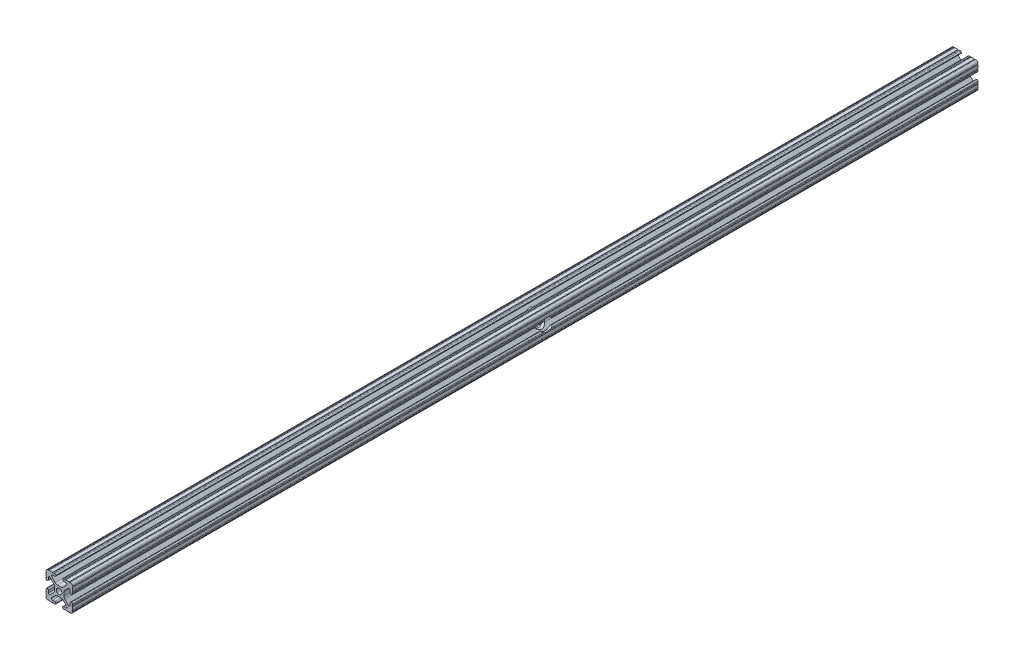
from build123d import *

# Parameters (mm, degrees)
SKETCH1_R               = 2.6035
EXTRUDE1_DEPTH          = 1219.2
SKETCH2_W               = 67.562409857
SKETCH2_H               = 369.908237117
CUT_EXTRUDE2_DEPTH      = 26.4
SKETCH3_R               = 6
CUT_EXTRUDE3_DEPTH      = 9.1915
CUT_EXTRUDE3_DEPTH_BACK = 18.2085


with BuildPart() as part:
    # Sketch1 → Extrude1 (new body)
    with BuildSketch(Plane.XY):
        with BuildLine():
            Line((-7.207036008, 8.724370562), (-3.898272566, 5.423169045))
            ThreePointArc((-3.898272566, 5.423169045), (-2.869120213, 4.736787962), (-1.655778399, 4.4958))
            Line((-1.655778399, 4.4958), (1.655778399, 4.4958))
            ThreePointArc((1.655778399, 4.4958), (2.869120213, 4.736787962), (3.898272566, 5.423169045))
            Line((3.898272566, 5.423169045), (7.207036008, 8.724370562))
            ThreePointArc((7.207036008, 8.724370562), (7.432222385, 9.85140422), (6.476788598, 10.4902))
            Line((6.476788598, 10.4902), (4.287512407, 10.4902))
            ThreePointArc((4.287512407, 10.4902), (3.54574862, 10.79744862), (3.2385, 11.539212407))
            Line((3.2385, 11.539212407), (3.2385, 11.650987593))
            ThreePointArc((3.2385, 11.650987593), (3.54574862, 12.39275138), (4.287512407, 12.7))
            Line((4.287512407, 12.7), (5.317126718, 12.7))
            ThreePointArc((5.317126718, 12.7), (5.825126718, 12.192), (6.333126718, 12.7))
            Line((6.333126718, 12.7), (9.550443118, 12.7))
            ThreePointArc((9.550443118, 12.7), (10.058366869, 12.192000006), (10.566443095, 12.699847501))
            ThreePointArc((10.566443095, 12.699847501), (12.082537762, 12.08250727), (12.699846982, 10.566399977))
            ThreePointArc((12.699846982, 10.566399977), (12.192000006, 10.058323491), (12.7, 9.5504))
            Line((12.7, 9.5504), (12.7, 6.3330836))
            ThreePointArc((12.7, 6.3330836), (12.192, 5.8250836), (12.7, 5.3170836))
            Line((12.7, 5.3170836), (12.7, 4.287469289))
            ThreePointArc((12.7, 4.287469289), (12.39275138, 3.545705502), (11.650987593, 3.238456882))
            Line((11.650987593, 3.238456882), (11.539212407, 3.238456882))
            ThreePointArc((11.539212407, 3.238456882), (10.79744862, 3.545705502), (10.4902, 4.287469289))
            Line((10.4902, 4.287469289), (10.4902, 6.402089023))
            ThreePointArc((10.4902, 6.402089023), (9.856505071, 7.351067942), (8.737131347, 7.129408934))
            Line((8.737131347, 7.129408934), (5.441005833, 3.840816462))
            ThreePointArc((5.441005833, 3.840816462), (4.750877967, 2.809883091), (4.5085, 1.593185507))
            Line((4.5085, 1.593185507), (4.5085, -1.593185507))
            ThreePointArc((4.5085, -1.593185507), (4.750877967, -2.809883091), (5.441005833, -3.840816462))
            Line((5.441005833, -3.840816462), (8.737131347, -7.129408934))
            ThreePointArc((8.737131347, -7.129408934), (9.856505071, -7.351067942), (10.4902, -6.402089023))
            Line((10.4902, -6.402089023), (10.4902, -4.287469289))
            ThreePointArc((10.4902, -4.287469289), (10.79744862, -3.545705502), (11.539212407, -3.238456882))
            Line((11.539212407, -3.238456882), (11.650987593, -3.238456882))
            ThreePointArc((11.650987593, -3.238456882), (12.39275138, -3.545705502), (12.7, -4.287469289))
            Line((12.7, -4.287469289), (12.7, -5.3170836))
            ThreePointArc((12.7, -5.3170836), (12.192, -5.8250836), (12.7, -6.3330836))
            Line((12.7, -6.3330836), (12.7, -9.5504))
            ThreePointArc((12.7, -9.5504), (12.192000006, -10.058323491), (12.699846982, -10.566399977))
            ThreePointArc((12.699846982, -10.566399977), (12.082537762, -12.08250727), (10.566443095, -12.699847501))
            ThreePointArc((10.566443095, -12.699847501), (10.058366869, -12.192000006), (9.550443118, -12.7))
            Line((9.550443118, -12.7), (6.333126718, -12.7))
            ThreePointArc((6.333126718, -12.7), (5.825126718, -12.192), (5.317126718, -12.7))
            Line((5.317126718, -12.7), (4.287512407, -12.7))
            ThreePointArc((4.287512407, -12.7), (3.54574862, -12.39275138), (3.2385, -11.650987593))
            Line((3.2385, -11.650987593), (3.2385, -11.539212407))
            ThreePointArc((3.2385, -11.539212407), (3.54574862, -10.79744862), (4.287512407, -10.4902))
            Line((4.287512407, -10.4902), (6.416408329, -10.4902))
            ThreePointArc((6.416408329, -10.4902), (7.41473083, -9.822813117), (7.179650497, -8.645192506))
            Line((7.179650497, -8.645192506), (3.952270251, -5.423690499))
            ThreePointArc((3.952270251, -5.423690499), (2.922936451, -4.736929036), (1.709253557, -4.4958))
            Line((1.709253557, -4.4958), (-1.709253557, -4.4958))
            ThreePointArc((-1.709253557, -4.4958), (-2.922936451, -4.736929036), (-3.952270251, -5.423690499))
            Line((-3.952270251, -5.423690499), (-7.179650497, -8.645192506))
            ThreePointArc((-7.179650497, -8.645192506), (-7.41473083, -9.822813117), (-6.416408329, -10.4902))
            Line((-6.416408329, -10.4902), (-4.287512407, -10.4902))
            ThreePointArc((-4.287512407, -10.4902), (-3.54574862, -10.79744862), (-3.2385, -11.539212407))
            Line((-3.2385, -11.539212407), (-3.2385, -11.650987593))
            ThreePointArc((-3.2385, -11.650987593), (-3.54574862, -12.39275138), (-4.287512407, -12.7))
            Line((-4.287512407, -12.7), (-5.317126718, -12.7))
            ThreePointArc((-5.317126718, -12.7), (-5.825126718, -12.192), (-6.333126718, -12.7))
            Line((-6.333126718, -12.7), (-9.550443118, -12.7))
            ThreePointArc((-9.550443118, -12.7), (-10.058366869, -12.192000006), (-10.566443095, -12.699847501))
            ThreePointArc((-10.566443095, -12.699847501), (-12.082537762, -12.08250727), (-12.699846982, -10.566399977))
            ThreePointArc((-12.699846982, -10.566399977), (-12.192000006, -10.058323491), (-12.7, -9.5504))
            Line((-12.7, -9.5504), (-12.7, -6.3330836))
            ThreePointArc((-12.7, -6.3330836), (-12.192, -5.8250836), (-12.7, -5.3170836))
            Line((-12.7, -5.3170836), (-12.7, -4.287469289))
            ThreePointArc((-12.7, -4.287469289), (-12.39275138, -3.545705502), (-11.650987593, -3.238456882))
            Line((-11.650987593, -3.238456882), (-11.539212407, -3.238456882))
            ThreePointArc((-11.539212407, -3.238456882), (-10.79744862, -3.545705502), (-10.4902, -4.287469289))
            Line((-10.4902, -4.287469289), (-10.4902, -6.402089023))
            ThreePointArc((-10.4902, -6.402089023), (-9.856505071, -7.351067942), (-8.737131347, -7.129408934))
            Line((-8.737131347, -7.129408934), (-5.441005833, -3.840816462))
            ThreePointArc((-5.441005833, -3.840816462), (-4.750877967, -2.809883091), (-4.5085, -1.593185507))
            Line((-4.5085, -1.593185507), (-4.5085, 1.593185507))
            ThreePointArc((-4.5085, 1.593185507), (-4.750877967, 2.809883091), (-5.441005833, 3.840816462))
            Line((-5.441005833, 3.840816462), (-8.737131347, 7.129408934))
            ThreePointArc((-8.737131347, 7.129408934), (-9.856505071, 7.351067942), (-10.4902, 6.402089023))
            Line((-10.4902, 6.402089023), (-10.4902, 4.287469289))
            ThreePointArc((-10.4902, 4.287469289), (-10.79744862, 3.545705502), (-11.539212407, 3.238456882))
            Line((-11.539212407, 3.238456882), (-11.650987593, 3.238456882))
            ThreePointArc((-11.650987593, 3.238456882), (-12.39275138, 3.545705502), (-12.7, 4.287469289))
            Line((-12.7, 4.287469289), (-12.7, 5.3170836))
            ThreePointArc((-12.7, 5.3170836), (-12.192, 5.8250836), (-12.7, 6.3330836))
            Line((-12.7, 6.3330836), (-12.7, 9.5504))
            ThreePointArc((-12.7, 9.5504), (-12.192000006, 10.058323491), (-12.699846982, 10.566399977))
            ThreePointArc((-12.699846982, 10.566399977), (-12.082537762, 12.08250727), (-10.566443095, 12.699847501))
            ThreePointArc((-10.566443095, 12.699847501), (-10.058366869, 12.192000006), (-9.550443118, 12.7))
            Line((-9.550443118, 12.7), (-6.333126718, 12.7))
            ThreePointArc((-6.333126718, 12.7), (-5.825126718, 12.192), (-5.317126718, 12.7))
            Line((-5.317126718, 12.7), (-4.287512407, 12.7))
            ThreePointArc((-4.287512407, 12.7), (-3.54574862, 12.39275138), (-3.2385, 11.650987593))
            Line((-3.2385, 11.650987593), (-3.2385, 11.539212407))
            ThreePointArc((-3.2385, 11.539212407), (-3.54574862, 10.79744862), (-4.287512407, 10.4902))
            Line((-4.287512407, 10.4902), (-6.476788598, 10.4902))
            ThreePointArc((-6.476788598, 10.4902), (-7.432222385, 9.85140422), (-7.207036008, 8.724370562))
        make_face()
        Circle(SKETCH1_R, mode=Mode.SUBTRACT)
    extrude(amount=-EXTRUDE1_DEPTH)

    # Sketch2 → Cut-Extrude2 (cut, through all)
    with BuildSketch(Plane(origin=(0, 12.7, 0), x_dir=(1, 0, 0), z_dir=(0, 1, 0))):
        with Locations((-12.93218868, 1054.954118558)):
            Rectangle(SKETCH2_W, SKETCH2_H)
    extrude(amount=-CUT_EXTRUDE2_DEPTH, mode=Mode.SUBTRACT)

    # Sketch3 → Cut-Extrude3 (cut, two sides)
    with BuildSketch(Plane(origin=(4.5085, 0, 0), x_dir=(0, 0, -1), z_dir=(1, 0, 0))) as cut_extrude3_sk:
        with Locations((456.1, 0)):
            Circle(SKETCH3_R)
    extrude(amount=CUT_EXTRUDE3_DEPTH, mode=Mode.SUBTRACT)
    extrude(cut_extrude3_sk.sketch, amount=-CUT_EXTRUDE3_DEPTH_BACK, mode=Mode.SUBTRACT)


solid = part.part
